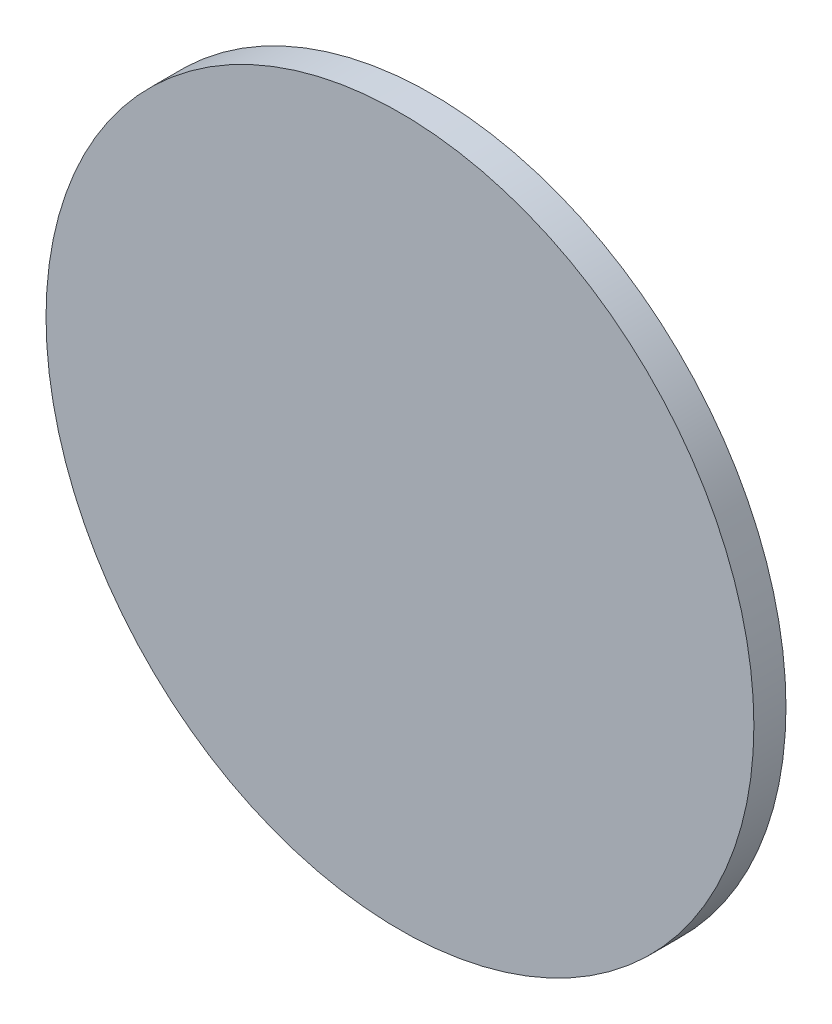
from build123d import *

# Parameters (mm, degrees)
SKETCH1_R           = 75
BOSS_EXTRUDE1_DEPTH = 6.8


with BuildPart() as part:
    # Sketch1 → Boss-Extrude1 (new body)
    with BuildSketch(Plane.XY):
        Circle(SKETCH1_R)
    extrude(amount=BOSS_EXTRUDE1_DEPTH)


solid = part.part
